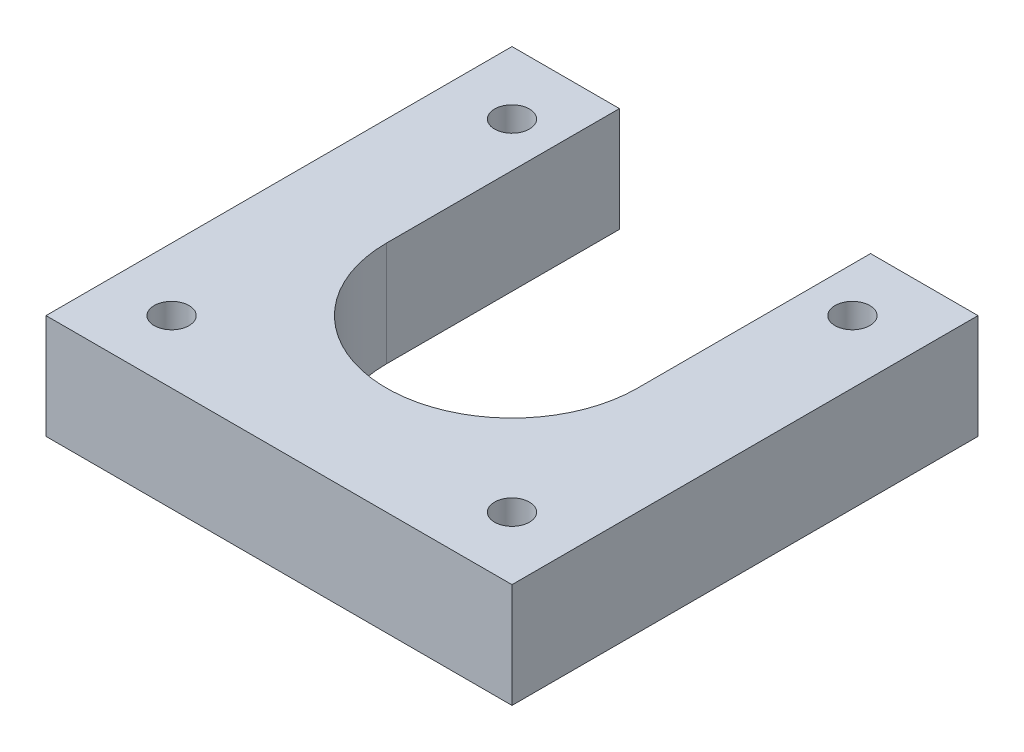
from build123d import *

# Parameters (mm, degrees)
SKETCH1_R           = 1.5875
BOSS_EXTRUDE1_DEPTH = 9.525


with BuildPart() as part:
    # Sketch1 → Boss-Extrude1 (new body)
    with BuildSketch(Plane(origin=(0, 0, 0), x_dir=(1, 0, 0), z_dir=(0, 1, 0))):
        with BuildLine():
            Line((0, 0), (42.418, 0))
            Line((42.418, 0), (42.418, 42.418))
            Line((42.418, 42.418), (32.639, 42.418))
            Line((32.639, 42.418), (32.639, 21.209))
            ThreePointArc((32.639, 21.209), (21.209, 9.779), (9.779, 21.209))
            Line((9.779, 21.209), (9.779, 42.418))
            Line((9.779, 42.418), (0, 42.418))
            Line((0, 42.418), (0, 0))
        make_face()
        with Locations((5.715, 36.703)):
            Circle(SKETCH1_R, mode=Mode.SUBTRACT)
        with Locations((36.703, 36.703)):
            Circle(SKETCH1_R, mode=Mode.SUBTRACT)
        with Locations((36.703, 5.715)):
            Circle(SKETCH1_R, mode=Mode.SUBTRACT)
        with Locations((5.715, 5.715)):
            Circle(SKETCH1_R, mode=Mode.SUBTRACT)
    extrude(amount=BOSS_EXTRUDE1_DEPTH)


solid = part.part
